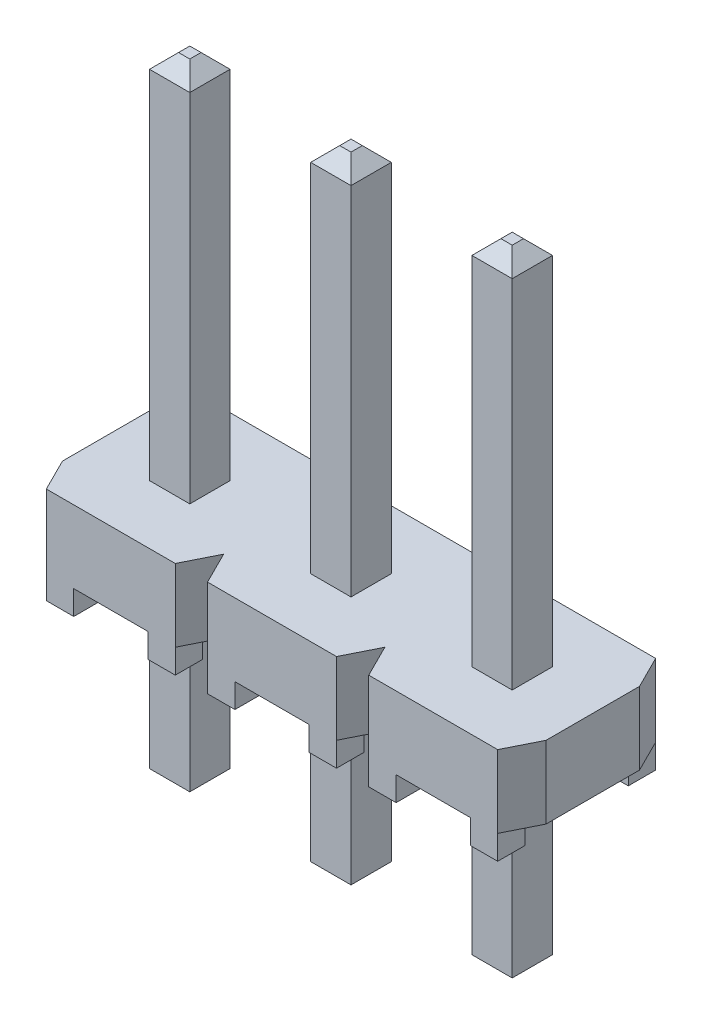
from build123d import *

# Parameters (mm, degrees)
SKETCH1_W                        = 7.62
SKETCH1_H                        = 2.4892
BASE_EXTRUDE_DEPTH               = 0.5715
SNAP_GROOVES_DEPTH               = 2.143
SKETCH4_W                        = 0.4318
SKETCH4_H                        = 0.4318
STANDOFFS_DEPTH                  = 0.381
POSITION_PATTERN_COUNT           = 3
POSITION_PATTERN_PITCH           = 2.54
SKETCH5_W                        = 0.635
SKETCH5_H                        = 10
TERMINAL_TH_DEPTH                = 0.3175
T1_TIP1_SIZE                     = 0.2286
TERMINAL_PATTERN_COUNT           = 3
TERMINAL_PATTERN_PITCH           = 2.54
T1_TIP1_OF_TERMINAL_PATTERN_SIZE = 0.2286


with BuildPart() as part:
    # Sketch1 → Base-Extrude (new body, symmetric)
    with BuildSketch(Plane(origin=(0, 0, 0), x_dir=(1, 0, 0), z_dir=(0, 1, 0))):
        Rectangle(SKETCH1_W, SKETCH1_H)
    extrude(amount=BASE_EXTRUDE_DEPTH, both=True)

    # Sketch3 → Snap Grooves (cut, through all)
    with BuildSketch(Plane(origin=(0, 0.5715, 0), x_dir=(-1, 0, 0), z_dir=(0, 1, 0))):
        Polygon((1.016, 1.2446), (1.524, 1.2446), (1.27, 0.7366), align=None)
        Polygon((1.016, -1.2446), (1.524, -1.2446), (1.27, -0.7366), align=None)
        Polygon((3.81, -0.7366), (4.064, -1.2446), (3.556, -1.2446), align=None)
        Polygon((3.81, 0.7366), (4.064, 1.2446), (3.556, 1.2446), align=None)
    snap_grooves = extrude(amount=-SNAP_GROOVES_DEPTH, mode=Mode.SUBTRACT)

    # Sketch4 → Standoffs (add)
    with BuildSketch(Plane.XZ.offset(0.5715)):
        with Locations((-3.3401, 1.0287)):
            Rectangle(SKETCH4_W, SKETCH4_H)
        with Locations((-1.7399, 1.0287)):
            Rectangle(SKETCH4_W, SKETCH4_H)
        with Locations((-1.7399, -1.0287)):
            Rectangle(SKETCH4_W, SKETCH4_H)
        with Locations((-3.3401, -1.0287)):
            Rectangle(SKETCH4_W, SKETCH4_H)
    standoffs = extrude(amount=STANDOFFS_DEPTH)

    # Position Pattern: Snap Grooves, Standoffs ×3
    with Locations(*[(i * POSITION_PATTERN_PITCH, 0, 0) for i in range(1, POSITION_PATTERN_COUNT)]):
        add(snap_grooves, mode=Mode.SUBTRACT)
        add(standoffs)

    # Sketch5 → Terminal -TH (add, symmetric)
    with BuildSketch(Plane.ZY.offset(2.54)):
        with Locations((0, 1.4135)):
            Rectangle(SKETCH5_W, SKETCH5_H)
    terminal_th = extrude(amount=TERMINAL_TH_DEPTH, both=True)

    # T1 Tip1
    t1_tip1_edges = [part.edges().sort_by_distance(p)[0] for p in [
        (-2.54, -3.5865, 0.3175),
        (-2.8575, -3.5865, 0),
        (-2.54, 6.4135, -0.3175),
        (-2.2225, -3.5865, 0),
        (-2.54, -3.5865, -0.3175),
        (-2.2225, 6.4135, 0),
        (-2.54, 6.4135, 0.3175),
        (-2.8575, 6.4135, 0),
    ]]
    chamfer(t1_tip1_edges, length=T1_TIP1_SIZE)

    # Terminal Pattern: Terminal -TH ×3
    with Locations(*[(i * TERMINAL_PATTERN_PITCH, 0, 0) for i in range(1, TERMINAL_PATTERN_COUNT)]):
        add(terminal_th)

    # T1 Tip1 of Terminal Pattern
    t1_tip1_of_terminal_pattern_edges = [part.edges().sort_by_distance(p)[0] for p in [
        (0, -3.5865, 0.3175),
        (-0.3175, -3.5865, 0),
        (0, 6.4135, -0.3175),
        (0.3175, -3.5865, 0),
        (0, -3.5865, -0.3175),
        (0.3175, 6.4135, 0),
        (0, 6.4135, 0.3175),
        (-0.3175, 6.4135, 0),
        (2.54, -3.5865, 0.3175),
        (2.2225, -3.5865, 0),
        (2.54, 6.4135, -0.3175),
        (2.8575, -3.5865, 0),
        (2.54, -3.5865, -0.3175),
        (2.8575, 6.4135, 0),
        (2.54, 6.4135, 0.3175),
        (2.2225, 6.4135, 0),
    ]]
    chamfer(t1_tip1_of_terminal_pattern_edges, length=T1_TIP1_OF_TERMINAL_PATTERN_SIZE)


solid = part.part
